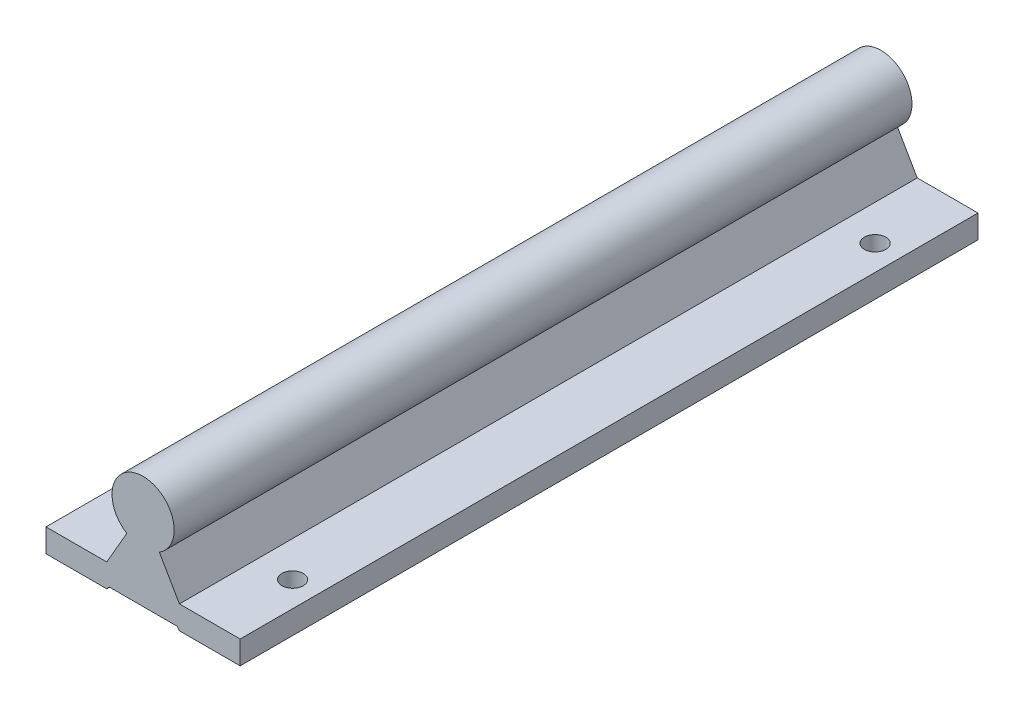
from build123d import *

# Parameters (mm, degrees)
SKETCH_2_R                  = 8
EXTRUDE_2_DEPTH             = 190
EXTRUDE_3_DEPTH             = 190
SKETCH_7_R                  = 2.75
CUT_EXTRUDE_1_DEPTH         = 194.107443641
HOLE_WIZARD_M51_D           = 5.3
HOLE_WIZARD_M51_DEPTH       = 18
HOLE_WIZARD_M51_CBORE_D     = 10
HOLE_WIZARD_M51_CBORE_DEPTH = 5
HOLE_WIZARD_M51_TIP         = 1.59228064


with BuildPart() as part:
    # Эскиз2 → Бобышка-Вытянуть2 (new body)
    with BuildSketch(Plane.XY):
        Circle(SKETCH_2_R)
    extrude(amount=EXTRUDE_2_DEPTH)

    # Эскиз2<4> → Бобышка-Вытянуть3 (add)
    with BuildSketch(Plane.XY):
        with BuildLine():
            Line((9.355, -15.779924087), (4.181941588, -6.819924087))
            ThreePointArc((4.181941588, -6.819924087), (0, -8), (-4.181941588, -6.819924087))
            Line((-4.181941588, -6.819924087), (-9.355, -15.779924087))
            Line((-9.355, -15.779924087), (-25, -15.779924087))
            Line((-25, -15.779924087), (-25, -21.779924087))
            Line((-25, -21.779924087), (-9.355, -21.779924087))
            Line((-9.355, -21.779924087), (-8.748067357, -21.051410397))
            Line((-8.748067357, -21.051410397), (8.748067357, -21.051410397))
            Line((8.748067357, -21.051410397), (9.355, -21.779924087))
            Line((9.355, -21.779924087), (25, -21.779924087))
            Line((25, -21.779924087), (25, -15.779924087))
            Line((25, -15.779924087), (9.355, -15.779924087))
        make_face()
    extrude(amount=EXTRUDE_3_DEPTH)

    # Эскиз7 → Вырез-Вытянуть1 (cut, through all)
    with BuildSketch(Plane(origin=(0, -15.779924087, 0), x_dir=(1, 0, 0), z_dir=(0, 1, 0))):
        with Locations((-18.5, -170)):
            Circle(SKETCH_7_R)
        with Locations((18.5, -170)):
            Circle(SKETCH_7_R)
        with Locations((18.5, -20)):
            Circle(SKETCH_7_R)
        with Locations((-18.5, -20)):
            Circle(SKETCH_7_R)
    extrude(amount=-CUT_EXTRUDE_1_DEPTH, mode=Mode.SUBTRACT)

    # Цековка для винта с внутренним шестигранником M51
    with Locations(Plane(origin=(0, -21.051410397, 0), x_dir=(-1, 0, 0), z_dir=(0, -1, 0))):
        with Locations((0, -20), (0, -170)):
            CounterBoreHole(HOLE_WIZARD_M51_D / 2, HOLE_WIZARD_M51_CBORE_D / 2, HOLE_WIZARD_M51_CBORE_DEPTH, depth=HOLE_WIZARD_M51_DEPTH)
            with Locations((0, 0, -(HOLE_WIZARD_M51_DEPTH + HOLE_WIZARD_M51_TIP / 2))):  # 118° drill point
                Cone(0, HOLE_WIZARD_M51_D / 2, HOLE_WIZARD_M51_TIP, mode=Mode.SUBTRACT)


solid = part.part
